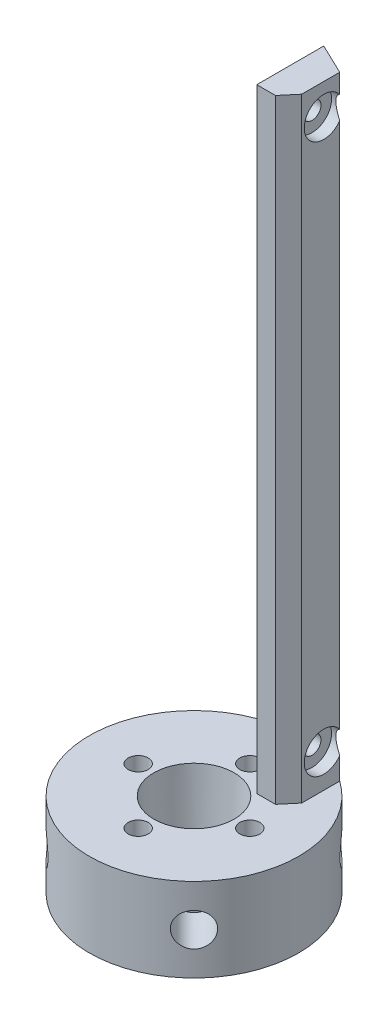
from build123d import *

# Parameters (mm, degrees)
SKIZZE1_R                        = 18.75
AUFSATZ_LINEAR_AUSTRAGEN1_DEPTH  = 15
SKIZZE2_R                        = 1.8
SKIZZE2_R_2                      = 1.65
SCHNITT_LINEAR_AUSTRAGEN1_DEPTH  = 16
AUFSATZ_LINEAR_AUSTRAGEN2_DEPTH  = 110
SKIZZE10_R                       = 3
SCHNITT_LINEAR_AUSTRAGEN5_DEPTH  = 8
KREISMUSTER1_COUNT               = 4
SKIZZE11_R                       = 1.6
SCHNITT_LINEAR_AUSTRAGEN6_DEPTH  = 14.5000001
SKIZZE16_R                       = 3.5
SCHNITT_LINEAR_AUSTRAGEN10_DEPTH = 2.1
SCHNITT_LINEAR_AUSTRAGEN11_DEPTH = 126.0000001


with BuildPart() as part:
    # Skizze1 → Aufsatz-Linear austragen1 (new body)
    with BuildSketch(Plane(origin=(0, 0, 0), x_dir=(1, 0, 0), z_dir=(0, 1, 0))):
        Circle(SKIZZE1_R)
    extrude(amount=AUFSATZ_LINEAR_AUSTRAGEN1_DEPTH)

    # Skizze2 → Schnitt-Linear austragen1 (cut, through all)
    with BuildSketch(Plane(origin=(0, 15, 0), x_dir=(1, 0, 0), z_dir=(0, 1, 0))):
        with Locations((0, 10)):
            Circle(SKIZZE2_R)
        with Locations((10, 0)):
            Circle(SKIZZE2_R)
        with Locations((0, -10)):
            Circle(SKIZZE2_R)
        with Locations((-10, 0)):
            Circle(SKIZZE2_R)
        Circle(SKIZZE2_R_2)
    extrude(amount=-SCHNITT_LINEAR_AUSTRAGEN1_DEPTH, mode=Mode.SUBTRACT)

    # Skizze4 → Aufsatz-Linear austragen2 (add)
    with BuildSketch(Plane(origin=(0, 15, 0), x_dir=(1, 0, 0), z_dir=(0, 1, 0))):
        with BuildLine():
            Line((5.25, 17), (5.25, 6))
            Line((5.25, 6), (8.607298894, 6))
            Line((8.607298894, 6), (10.750900369, 8.554644759))
            Line((10.750900369, 8.554644759), (10.750900369, 15.361661409))
            ThreePointArc((10.750900369, 15.361661409), (8.108477711, 16.906066639), (5.25, 18))
            Line((5.25, 18), (5.25, 17))
        make_face()
    extrude(amount=AUFSATZ_LINEAR_AUSTRAGEN2_DEPTH)

    # Skizze10 → Schnitt-Linear austragen5 (cut)
    with BuildSketch(Plane(origin=(13.258252147, 0, 13.258252147), x_dir=(0, -1, 0), z_dir=(0.707106781, 0, 0.707106781))):
        with Locations((-7.5, 0)):
            Circle(SKIZZE10_R)
    schnitt_linear_austragen5 = extrude(amount=-SCHNITT_LINEAR_AUSTRAGEN5_DEPTH, mode=Mode.SUBTRACT)

    # Kreismuster1: Schnitt-Linear austragen5 ×4 about axis
    kreismuster1_axis = Axis((0, 0, 0), (0, 1, 0))
    for i in range(1, KREISMUSTER1_COUNT):
        add(schnitt_linear_austragen5.rotate(kreismuster1_axis, i * 360 / KREISMUSTER1_COUNT), mode=Mode.SUBTRACT)

    # Skizze11 → Schnitt-Linear austragen6 (cut, through all)
    with BuildSketch(Plane.ZY.offset(-5.25)):
        with Locations((-12.5, 119.5)):
            Circle(SKIZZE11_R)
        with Locations((-12.5, 21)):
            Circle(SKIZZE11_R)
    extrude(amount=-SCHNITT_LINEAR_AUSTRAGEN6_DEPTH, mode=Mode.SUBTRACT)

    # Skizze16 → Schnitt-Linear austragen10 (cut)
    with BuildSketch(Plane(origin=(10.750900369, 0, 0), x_dir=(0, 0, -1), z_dir=(1, 0, 0))):
        with Locations((12.5, 119.5)):
            Circle(SKIZZE16_R)
        with Locations((12.5, 21)):
            Circle(SKIZZE16_R)
    extrude(amount=-SCHNITT_LINEAR_AUSTRAGEN10_DEPTH, mode=Mode.SUBTRACT)

    # Skizze17 → Schnitt-Linear austragen11 (cut, through all)
    with BuildSketch(Plane(origin=(0, 125, 0), x_dir=(1, 0, 0), z_dir=(0, 1, 0))):
        with BuildLine():
            Line((5.25, 18), (10.750900369, 15.361661409))
            ThreePointArc((10.750900369, 15.361661409), (8.108477711, 16.906066639), (5.25, 18))
        make_face()
    extrude(amount=-SCHNITT_LINEAR_AUSTRAGEN11_DEPTH, mode=Mode.SUBTRACT)

    # Skizze18 → Schnitt-Rotation1 (revolve, cut)
    with BuildSketch(Plane.XY):
        Polygon((0, 0), (6, 0), (7.2, 15), (0, 15), align=None)
    revolve(axis=Axis((0, 15, 0), (0, -1, 0)), mode=Mode.SUBTRACT)


solid = part.part
